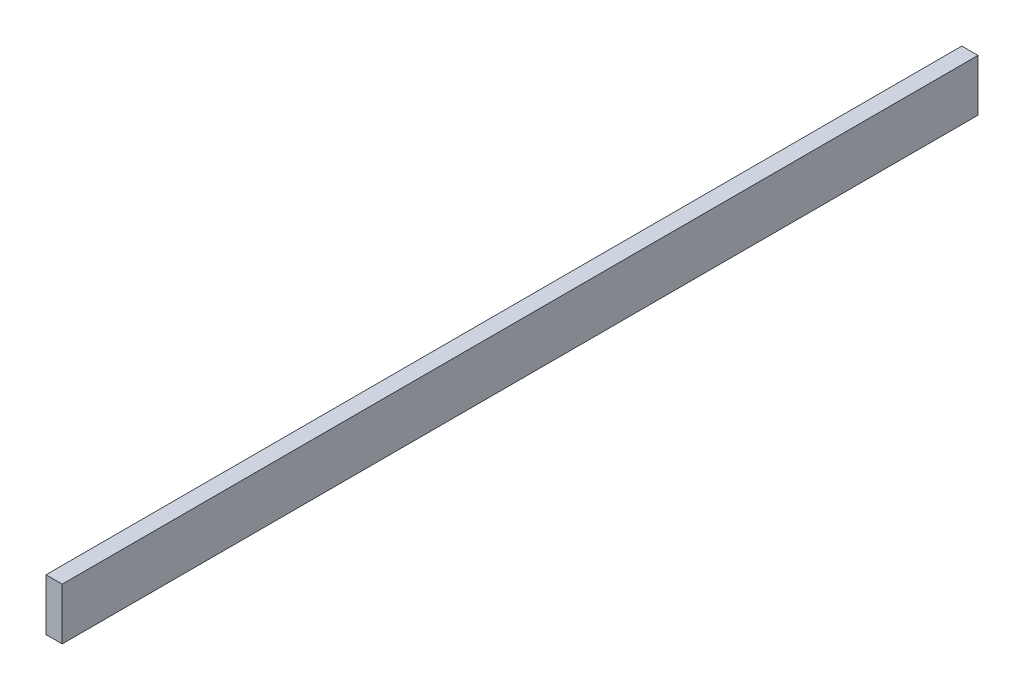
from build123d import *

# Parameters (mm, degrees)
SKETCH1_W           = 179.578
SKETCH1_H           = 10.16
BOSS_EXTRUDE1_DEPTH = 3.175


with BuildPart() as part:
    # Sketch1 → Boss-Extrude1 (new body)
    with BuildSketch(Plane(origin=(0, 0, 0), x_dir=(0, 0, -1), z_dir=(1, 0, 0))):
        Rectangle(SKETCH1_W, SKETCH1_H)
    extrude(amount=BOSS_EXTRUDE1_DEPTH)


solid = part.part
